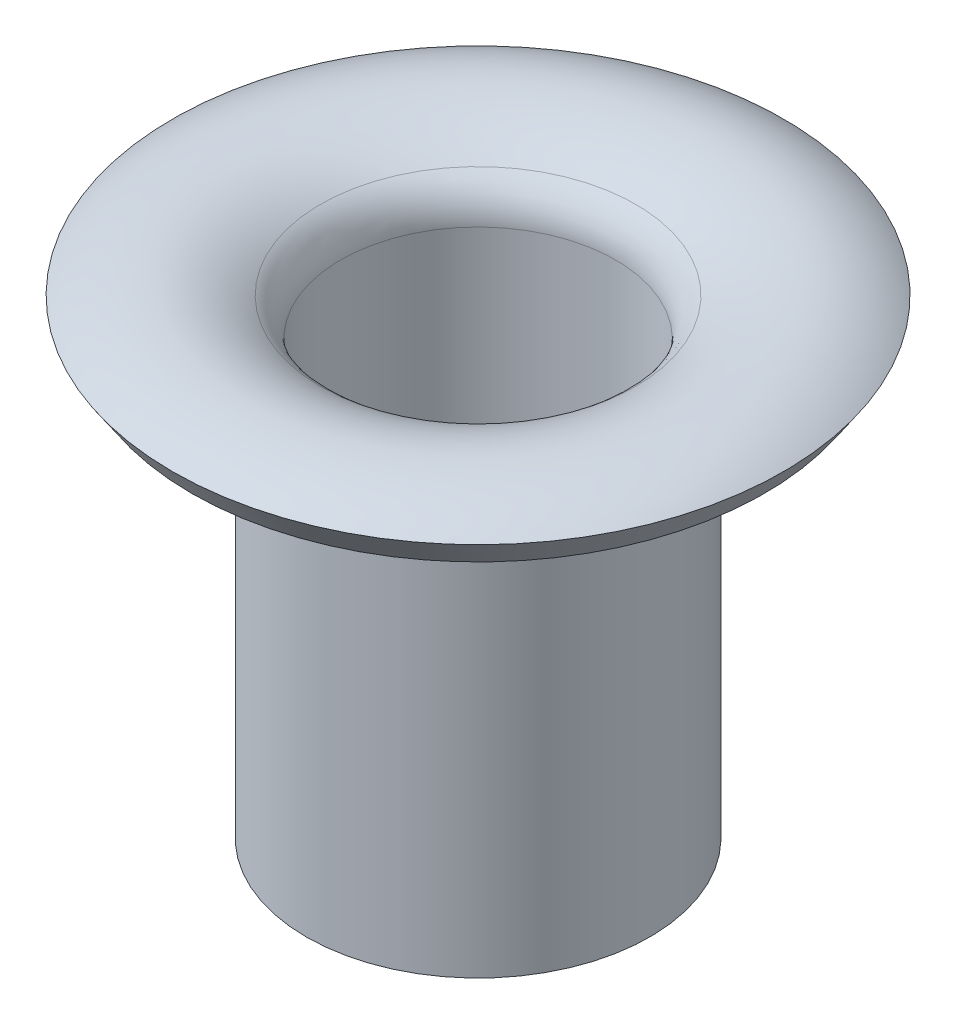
from build123d import *


with BuildPart() as part:
    # Esquisse2 → Révol.-Mince1 (revolve)
    with BuildSketch(Plane.XY, mode=Mode.PRIVATE) as r_vol_mince1_sk:
        with BuildLine():
            Line((1.5, -3.854094195), (1.5, -0.082948868))
            ThreePointArc((1.5, -0.082948868), (1.511724195, -0.03596608), (1.544147647, 0))
            ThreePointArc((1.544147647, 0), (2.022073823, 0.145905805), (2.5, 0))
            Line((2.5, 0), (2.66755706, 0.248846603))
            ThreePointArc((2.66755706, 0.248846603), (2.022073823, 0.445905805), (1.376590587, 0.248846603))
            ThreePointArc((1.376590587, 0.248846603), (1.246896782, 0.104982283), (1.2, -0.082948868))
            Line((1.2, -0.082948868), (1.2, -3.854094195))
            Line((1.2, -3.854094195), (1.5, -3.854094195))
        make_face()
    revolve(r_vol_mince1_sk.sketch.rotate(Axis((0, 0, 0), (0, -1, 0)), 90), axis=Axis((0, 0, 0), (0, -1, 0)))  # turned: the seam where the file's is


solid = part.part
